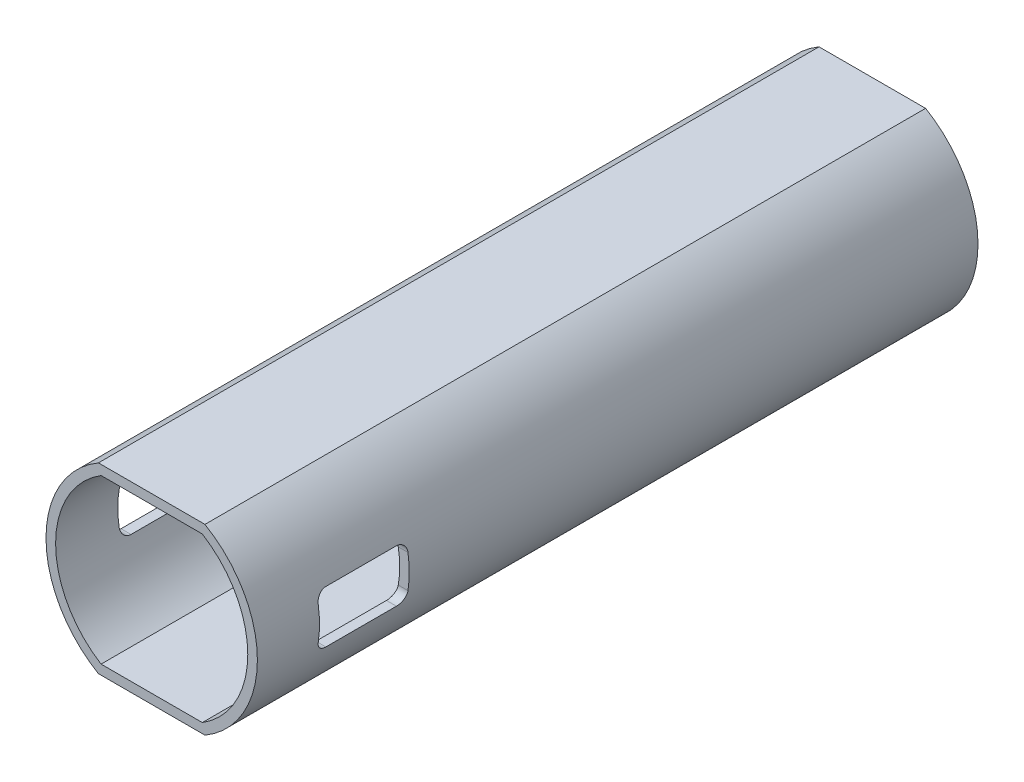
from build123d import *

# Parameters (mm, degrees)
BOSS_EXTRUDE1_DEPTH     = 150
CUT_EXTRUDE1_DEPTH      = 23
CUT_EXTRUDE1_DEPTH_BACK = 23
SCALE1_SCALE            = 0.5


with BuildPart() as part:
    # Sketch1 → Boss-Extrude1 (new body)
    with BuildSketch(Plane.XY):
        with BuildLine():
            Line((11.090536506, 19), (-11.090536506, 19))
            ThreePointArc((-11.090536506, 19), (-22, 0), (-11.090536506, -19))
            Line((-11.090536506, -19), (11.090536506, -19))
            ThreePointArc((11.090536506, -19), (22, 0), (11.090536506, 19))
        make_face()
        with BuildLine():
            Line((10.535653753, 17), (-10.535653753, 17))
            ThreePointArc((-10.535653753, 17), (-20, 0), (-10.535653753, -17))
            Line((-10.535653753, -17), (10.535653753, -17))
            ThreePointArc((10.535653753, -17), (20, 0), (10.535653753, 17))
        make_face(mode=Mode.SUBTRACT)
    extrude(amount=BOSS_EXTRUDE1_DEPTH)

    # Sketch2 → Cut-Extrude1 (cut, two sides)
    with BuildSketch(Plane(origin=(0, 0, 0), x_dir=(0, 0, -1), z_dir=(1, 0, 0))) as cut_extrude1_sk:
        with BuildLine():
            Line((-135.063632734, 5.44778031), (-120.375877862, 5.44778031))
            ThreePointArc((-120.375877862, 5.44778031), (-118.961664299, 4.861993873), (-118.375877862, 3.44778031))
            Line((-118.375877862, 3.44778031), (-118.375877862, -3.44778031))
            ThreePointArc((-118.375877862, -3.44778031), (-118.961664299, -4.861993873), (-120.375877862, -5.44778031))
            Line((-120.375877862, -5.44778031), (-135.063632734, -5.44778031))
            ThreePointArc((-135.063632734, -5.44778031), (-136.477846296, -4.861993873), (-137.063632734, -3.44778031))
            Line((-137.063632734, -3.44778031), (-137.063632734, 3.44778031))
            ThreePointArc((-137.063632734, 3.44778031), (-136.477846296, 4.861993873), (-135.063632734, 5.44778031))
        make_face()
    extrude(amount=CUT_EXTRUDE1_DEPTH, mode=Mode.SUBTRACT)
    extrude(cut_extrude1_sk.sketch, amount=-CUT_EXTRUDE1_DEPTH_BACK, mode=Mode.SUBTRACT)


with BuildPart() as part_1:
    # Scale1: scaled about (-1.198e-06, 7.41e-07, 73.880063971)
    add(part.part.scale(SCALE1_SCALE).moved(Location((-5.99e-07, 3.7e-07, 36.940031985))))


solid = part_1.part
